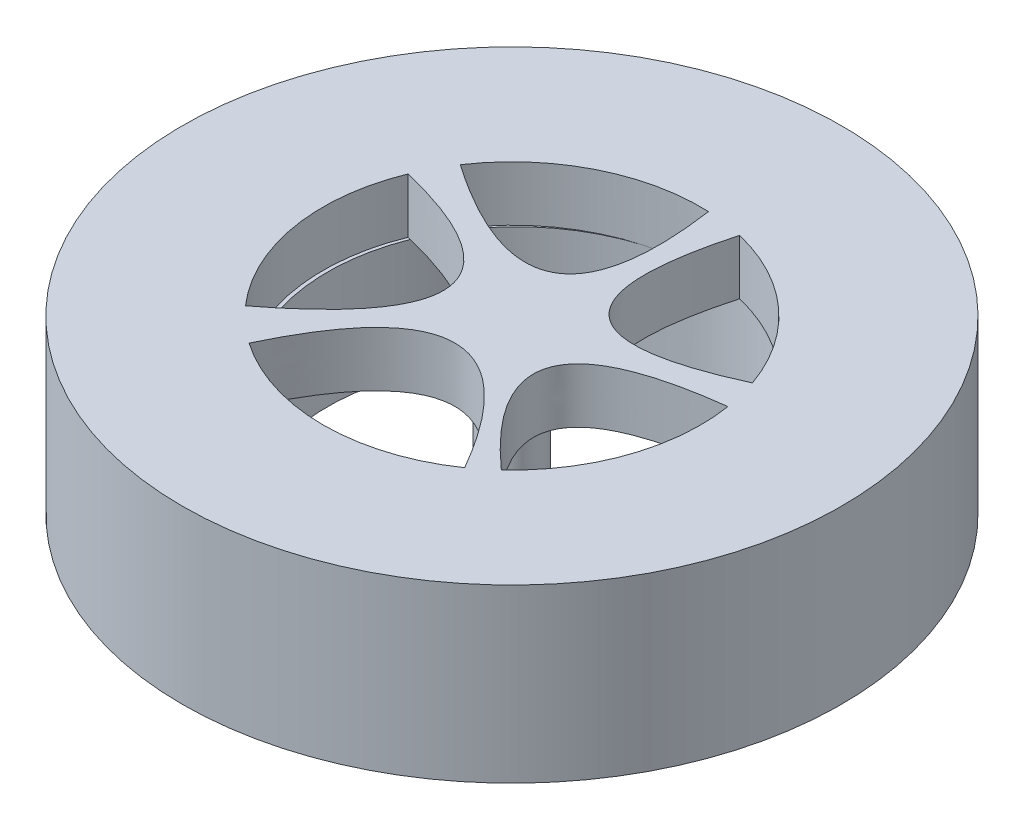
from build123d import *

# Parameters (mm, degrees)
SKETCH2_R           = 40
BOSS_EXTRUDE1_DEPTH = 25
SKETCH3_R           = 27.5
CUT_EXTRUDE1_DEPTH  = 17
CUT_EXTRUDE3_DEPTH  = 9
SKETCH5_R           = 4
BOSS_EXTRUDE3_DEPTH = 25
SKETCH6_R           = 2.5
CUT_EXTRUDE4_DEPTH  = 10
SKETCH18_R          = 48
SKETCH18_R_2        = 40
BOSS_EXTRUDE5_DEPTH = 25


with BuildPart() as part:
    # Sketch2 → Boss-Extrude1 (new body)
    with BuildSketch(Plane(origin=(0, 0, 0), x_dir=(1, 0, 0), z_dir=(0, 1, 0))):
        with Locations((-41.86871729, 18.12498584)):
            Circle(SKETCH2_R)
    extrude(amount=BOSS_EXTRUDE1_DEPTH)

    # Sketch3 → Cut-Extrude1 (cut)
    with BuildSketch(Plane.XZ):
        with Locations((-41.345752459, -18.274404363)):
            Circle(SKETCH3_R)
    extrude(amount=-CUT_EXTRUDE1_DEPTH, mode=Mode.SUBTRACT)

    # Sketch4 → Cut-Extrude3 (cut, through all)
    with BuildSketch(Plane.XZ.offset(-17)):
        with BuildLine():
            ThreePointArc((-14.70636998, -22.421133954), (-15.889488047, -9.10669066), (-23.210546195, 2.077059883))
            add(Edge.make_bspline(
                [(-23.210546195, 2.077059883), (-46.355723427, -18.546490673), (-14.70636998, -22.421133954)],
                knots=[0, 0, 0, 1, 1, 1], degree=2))
        make_face()
        with BuildLine():
            ThreePointArc((-35.453936971, -44.866350679), (-23.423134112, -38.521320345), (-15.904630116, -27.18678352))
            add(Edge.make_bspline(
                [(-15.904630116, -27.18678352), (-43.876407216, -14.328885453), (-35.453936971, -44.866350679)],
                knots=[0, 0, 0, 1, 1, 1], degree=2))
        make_face()
        with BuildLine():
            ThreePointArc((-64.70739494, -33.443105934), (-54.300273107, -42.654690689), (-40.717881586, -45.600894873))
            add(Edge.make_bspline(
                [(-40.717881586, -45.600894873), (-36.156523784, -13.602103875), (-64.70739494, -33.443105934)],
                knots=[0, 0, 0, 1, 1, 1], degree=2))
        make_face()
        with BuildLine():
            ThreePointArc((-62.550469834, 0), (-68.986764274, -13.557543689), (-67.346528808, -28.475402269))
            add(Edge.make_bspline(
                [(-67.346528808, -28.475402269), (-35.360422095, -20.710055245), (-62.550469834, 0)],
                knots=[0, 0, 0, 1, 1, 1], degree=2))
        make_face()
        with BuildLine():
            ThreePointArc((-26.174469517, 4.456878273), (-41.880660096, 9.375011567), (-57.58257302, 4.44323824))
            add(Edge.make_bspline(
                [(-57.58257302, 4.44323824), (-43.38243666, -25.570584632), (-26.174469517, 4.456878273)],
                knots=[0, 0, 0, 1, 1, 1], degree=2))
        make_face()
    extrude(amount=-CUT_EXTRUDE3_DEPTH, mode=Mode.SUBTRACT)

    # Sketch5 → Boss-Extrude3 (add)
    with BuildSketch(Plane.XZ.offset(-17)):
        with Locations((-41.86871729, -18.12498584)):
            Circle(SKETCH5_R)
    extrude(amount=BOSS_EXTRUDE3_DEPTH)

    # Sketch6 → Cut-Extrude4 (cut)
    with BuildSketch(Plane.XZ.offset(8)):
        with Locations((-41.86871729, -18.12498584)):
            Circle(SKETCH6_R)
    extrude(amount=-CUT_EXTRUDE4_DEPTH, mode=Mode.SUBTRACT)

    # Sketch18 → Boss-Extrude5 (add)
    with BuildSketch(Plane(origin=(0, 0, 0), x_dir=(1, 0, 0), z_dir=(0, 1, 0))):
        with Locations((-41.86871729, 18.12498584)):
            Circle(SKETCH18_R)
        with Locations((-41.86871729, 18.12498584)):
            Circle(SKETCH18_R_2, mode=Mode.SUBTRACT)
    extrude(amount=BOSS_EXTRUDE5_DEPTH)


solid = part.part
